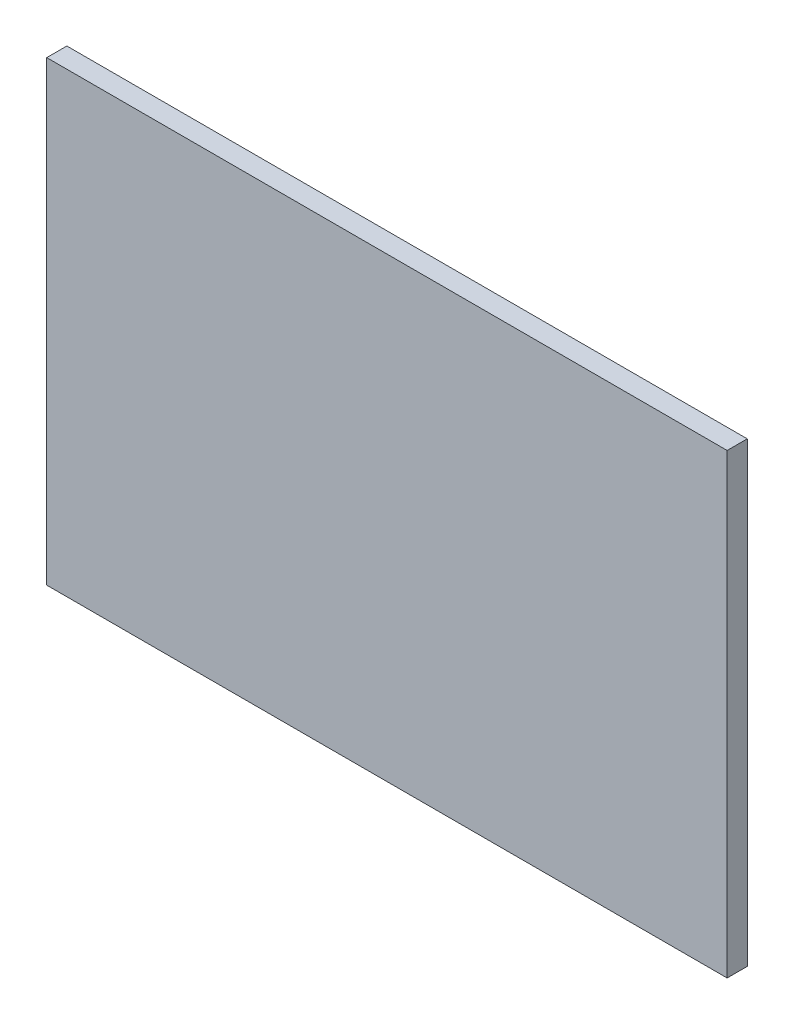
from build123d import *

# Parameters (mm, degrees)
ESQUISSE1_W        = 3000
ESQUISSE1_H        = 2000
BOSS_EXTRU_1_DEPTH = 20
ESQUISSE2_W        = 3044
ESQUISSE2_H        = 2044
ESQUISSE2_W_2      = 3000
ESQUISSE2_H_2      = 2000
BOSS_EXTRU_2_DEPTH = 90
ESQUISSE3_W        = 1800
ESQUISSE3_H        = 450
BOSS_EXTRU_3_DEPTH = 55
ESQUISSE4_W        = 15
ESQUISSE4_H        = 450
BOSS_EXTRU_4_DEPTH = 15


with BuildPart() as part:
    # Esquisse1 → Boss.-Extru.1 (new body)
    with BuildSketch(Plane.XY):
        with Locations((247.572815534, 339.805825243)):
            Rectangle(ESQUISSE1_W, ESQUISSE1_H)
    extrude(amount=BOSS_EXTRU_1_DEPTH)

    # Esquisse2 → Boss.-Extru.2 (add)
    with BuildSketch(Plane.XY.offset(20)):
        with Locations((247.572815534, 339.805825243)):
            Rectangle(ESQUISSE2_W, ESQUISSE2_H)
        with Locations((247.572815534, 339.805825243)):
            Rectangle(ESQUISSE2_W_2, ESQUISSE2_H_2, mode=Mode.SUBTRACT)
    extrude(amount=-BOSS_EXTRU_2_DEPTH)

    # Esquisse3 → Boss.-Extru.3 (add)
    with BuildSketch(Plane(origin=(0, 0, 0), x_dir=(-1, 0, 0), z_dir=(0, 0, -1))):
        with Locations((-247.572815534, 1114.805825243)):
            Rectangle(ESQUISSE3_W, ESQUISSE3_H)
    extrude(amount=BOSS_EXTRU_3_DEPTH)

    # Esquisse4 → Boss.-Extru.4 (add)
    with BuildSketch(Plane(origin=(0, 0, -55), x_dir=(-1, 0, 0), z_dir=(0, 0, -1))):
        with Locations((-1140.072815534, 1114.805825243)):
            Rectangle(ESQUISSE4_W, ESQUISSE4_H)
        with Locations((644.927184466, 1114.805825243)):
            Rectangle(ESQUISSE4_W, ESQUISSE4_H)
    extrude(amount=BOSS_EXTRU_4_DEPTH)


solid = part.part
